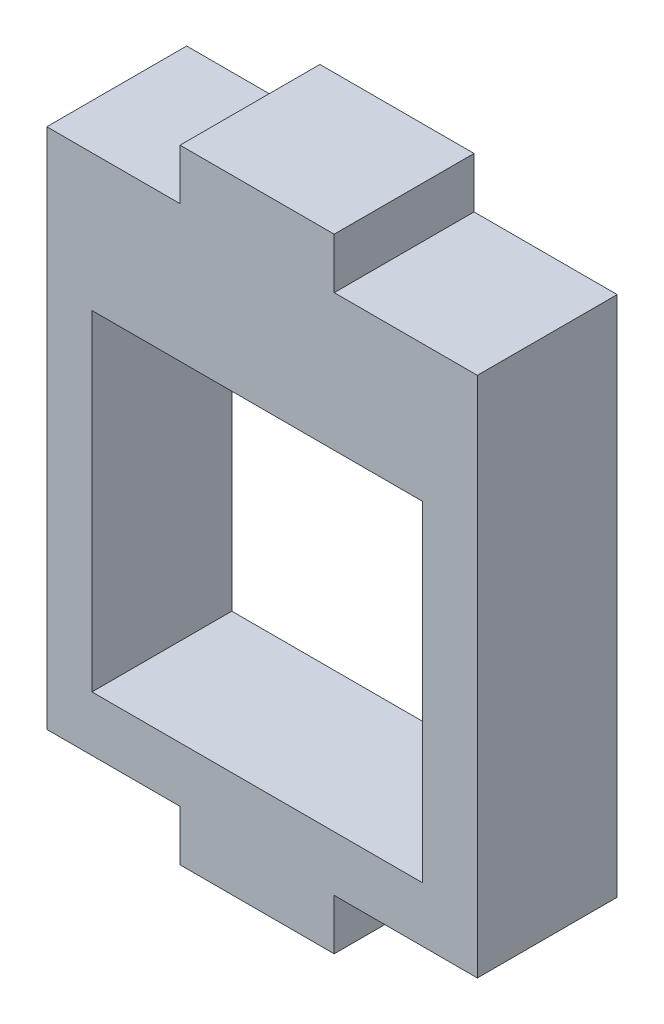
from build123d import *

# Parameters (mm, degrees)
BOSS_EXTRUDE1_DEPTH = 6.35
SKETCH2_W           = 20
SKETCH2_H           = 2.5
BOSS_EXTRUDE2_DEPTH = 6.35
SKETCH4_W           = 7
SKETCH4_H           = 2.3
BOSS_EXTRUDE3_DEPTH = 6.35
SKETCH5_W           = 0.45
SKETCH5_H           = 23.7
CUT_EXTRUDE1_DEPTH  = 10


with BuildPart() as part:
    # Sketch1 → Boss-Extrude1 (new body)
    with BuildSketch(Plane.XY):
        Polygon((-15.235299292, 17.883619427), (-15.235299292, 2.883619427), (-0.235299292, 2.883619427), (-0.235299292, 17.883619427), (2.264700708, 17.883619427), (2.264700708, 0.383619427), (-17.735299292, 0.383619427), (-17.735299292, 17.883619427), align=None)
    extrude(amount=BOSS_EXTRUDE1_DEPTH)

    # Sketch2 → Boss-Extrude2 (add, through all)
    with BuildSketch(Plane.XY):
        with Locations((-7.735299292, 19.133619427)):
            Rectangle(SKETCH2_W, SKETCH2_H)
    extrude(amount=BOSS_EXTRUDE2_DEPTH)

    # Sketch4 → Boss-Extrude3 (add)
    with BuildSketch(Plane.XY.offset(6.35)):
        Polygon((-17.735299292, 20.383619427), (2.264700708, 20.383619427), (2.264700708, 24.083619427), (-4.235299292, 24.083619427), (-4.235299292, 26.383619427), (-11.235299292, 26.383619427), (-11.235299292, 24.083619427), (-17.735299292, 24.083619427), align=None)
        with Locations((-7.735299292, -0.766380573)):
            Rectangle(SKETCH4_W, SKETCH4_H)
    extrude(amount=-BOSS_EXTRUDE3_DEPTH)

    # Sketch5 → Cut-Extrude1 (cut)
    with BuildSketch(Plane.XY.offset(6.35)):
        with Locations((-17.510299292, 12.233619427)):
            Rectangle(SKETCH5_W, SKETCH5_H)
    extrude(amount=-CUT_EXTRUDE1_DEPTH, mode=Mode.SUBTRACT)


solid = part.part
